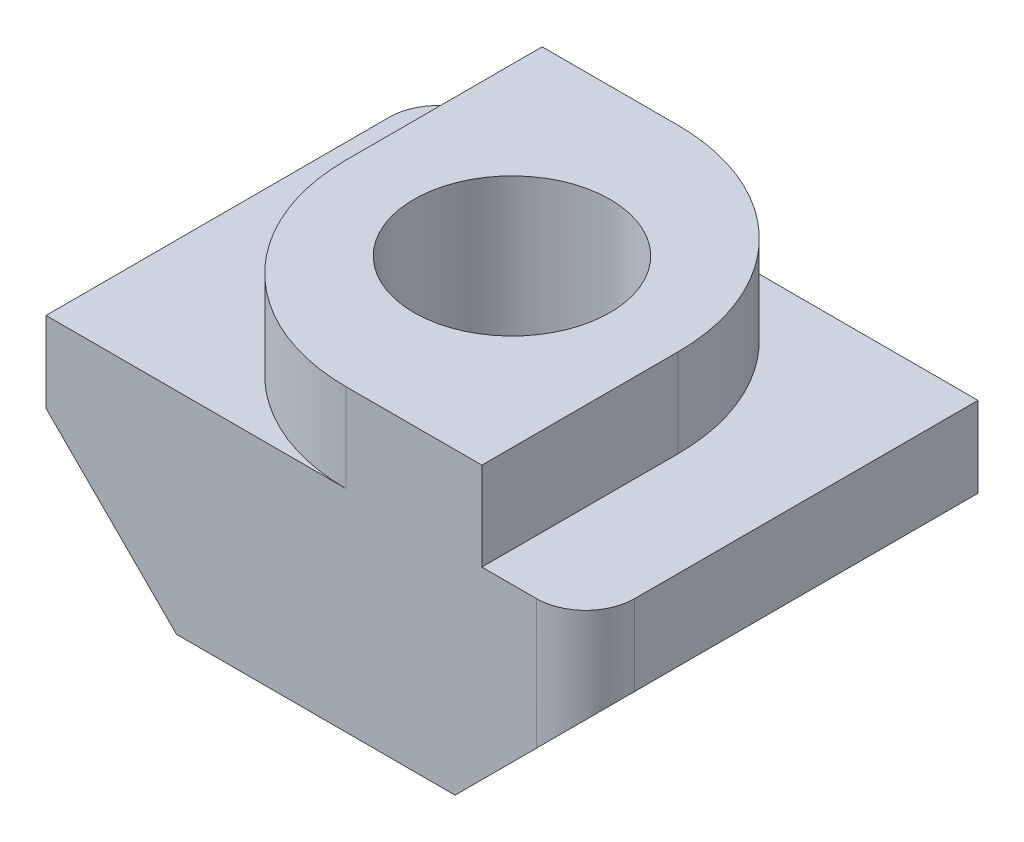
from build123d import *

# Parameters (mm, degrees)
SKETCH1_W           = 11
SKETCH1_H           = 8
SKETCH1_R           = 2
BOSS_EXTRUDE1_DEPTH = 4.3
CUT_EXTRUDE1_DEPTH  = 9
SKETCH3_W           = 6.77
SKETCH3_H           = 8
SKETCH3_R           = 2
BOSS_EXTRUDE2_DEPTH = 1.8
FILLET1_R           = 4
FILLET2_R           = 1


with BuildPart() as part:
    # Sketch1 → Boss-Extrude1 (new body)
    with BuildSketch(Plane(origin=(0, 0, 0), x_dir=(1, 0, 0), z_dir=(0, 1, 0))):
        Rectangle(SKETCH1_W, SKETCH1_H)
        Circle(SKETCH1_R, mode=Mode.SUBTRACT)
    extrude(amount=BOSS_EXTRUDE1_DEPTH)

    # Sketch2 → Cut-Extrude1 (cut, through all)
    with BuildSketch(Plane.XY.offset(4)):
        Polygon((-5.5, 2.66), (-2.84, 0), (-5.5, 0), align=None)
        Polygon((5.5, 2.66), (5.5, 0), (2.84, 0), align=None)
    extrude(amount=-CUT_EXTRUDE1_DEPTH, mode=Mode.SUBTRACT)

    # Sketch3 → Boss-Extrude2 (add)
    with BuildSketch(Plane(origin=(0, 4.3, 0), x_dir=(1, 0, 0), z_dir=(0, 1, 0))):
        Rectangle(SKETCH3_W, SKETCH3_H)
        Circle(SKETCH3_R, mode=Mode.SUBTRACT)
    extrude(amount=BOSS_EXTRUDE2_DEPTH)

    # Fillet1
    fillet1_edges = [part.edges().sort_by_distance(p)[0] for p in [
        (3.385, 5.2, -4),
        (-3.385, 5.2, 4),
    ]]
    fillet(fillet1_edges, radius=FILLET1_R)

    # Fillet2
    fillet2_edges = [part.edges().sort_by_distance(p)[0] for p in [
        (5.5, 3.48, 4),
        (-5.5, 3.48, -4),
    ]]
    fillet(fillet2_edges, radius=FILLET2_R)


solid = part.part
